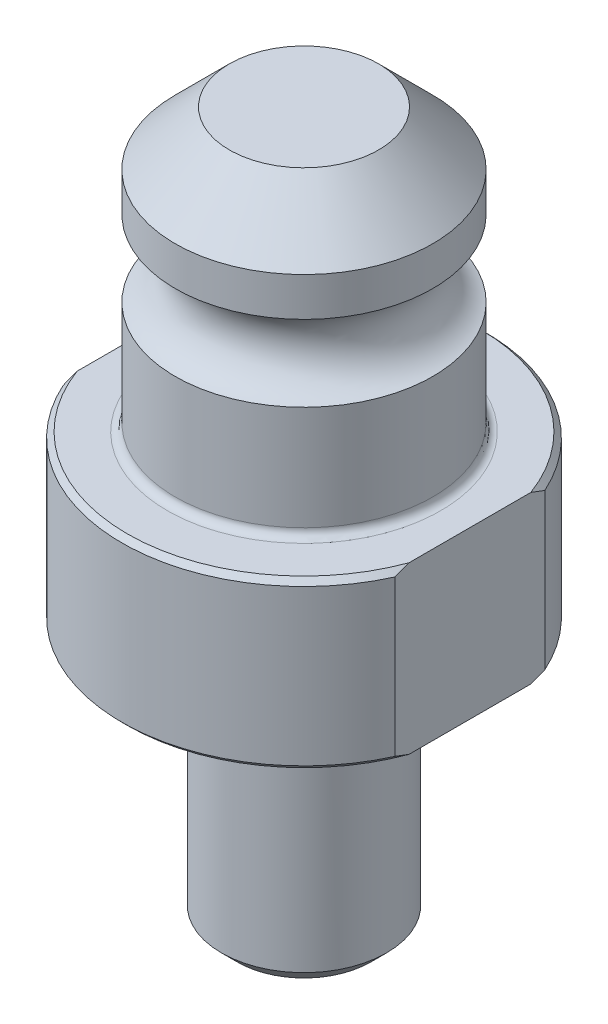
from build123d import *

# Parameters (mm, degrees)
CHAMFER1_SIZE      = 0.508
CHAMFER2_SIZE      = 1.524
CUT_EXTRUDE1_DEPTH = 41.9448
FILLET1_R          = 0.762


with BuildPart() as part:
    # Sketch1 → Revolve1 (revolve)
    with BuildSketch(Plane.XY):
        with BuildLine():
            Line((0, 43.0022), (0, -24.9936))
            Line((0, -24.9936), (-7.9375, -24.9936))
            Line((-7.9375, -24.9936), (-7.9375, -3.81))
            Line((-7.9375, -3.81), (-6.223, -3.81))
            Line((-6.223, -3.81), (-6.223, -1.27))
            ThreePointArc((-6.223, -1.27), (-6.594974388, -0.371974388), (-7.493, 0))
            Line((-7.493, 0), (-17.5006, 0))
            Line((-17.5006, 0), (-17.5006, 15.9512))
            Line((-17.5006, 15.9512), (-12.3825, 15.9512))
            Line((-12.3825, 15.9512), (-12.3825, 26.7462))
            ThreePointArc((-12.3825, 26.7462), (-9.652, 30.4038), (-12.3825, 34.0614))
            Line((-12.3825, 34.0614), (-12.3825, 37.7952))
            Line((-12.3825, 37.7952), (-7.1755, 43.0022))
            Line((-7.1755, 43.0022), (0, 43.0022))
        make_face()
    revolve(axis=Axis((0, -24.9936, 0), (0, -1, 0)))

    # Chamfer1
    chamfer1_edges = [part.edges().sort_by_distance(p)[0] for p in [
        (17.5006, 15.9512, 0),
        (17.5006, 0, 0),
    ]]
    chamfer(chamfer1_edges, length=CHAMFER1_SIZE)

    # Chamfer2
    chamfer2_edges = [part.edges().sort_by_distance(p)[0] for p in [
        (7.9375, -24.9936, 0),
    ]]
    chamfer(chamfer2_edges, length=CHAMFER2_SIZE)

    # Sketch2 → Cut-Extrude1 (cut, through all)
    with BuildSketch(Plane(origin=(0, 15.9512, 0), x_dir=(1, 0, 0), z_dir=(0, 1, 0))):
        with BuildLine():
            Line((-15.9512, 7.199320726), (-15.9512, -7.199320726))
            ThreePointArc((-15.9512, -7.199320726), (-17.5006, 0), (-15.9512, 7.199320726))
        make_face()
        with BuildLine():
            Line((15.9512, 7.199320726), (15.9512, -7.199320726))
            ThreePointArc((15.9512, -7.199320726), (17.5006, 0), (15.9512, 7.199320726))
        make_face()
    extrude(amount=-CUT_EXTRUDE1_DEPTH, mode=Mode.SUBTRACT)

    # Fillet1
    fillet1_edges = [part.edges().sort_by_distance(p)[0] for p in [
        (12.3825, 15.9512, 0),
    ]]
    fillet(fillet1_edges, radius=FILLET1_R)


solid = part.part
